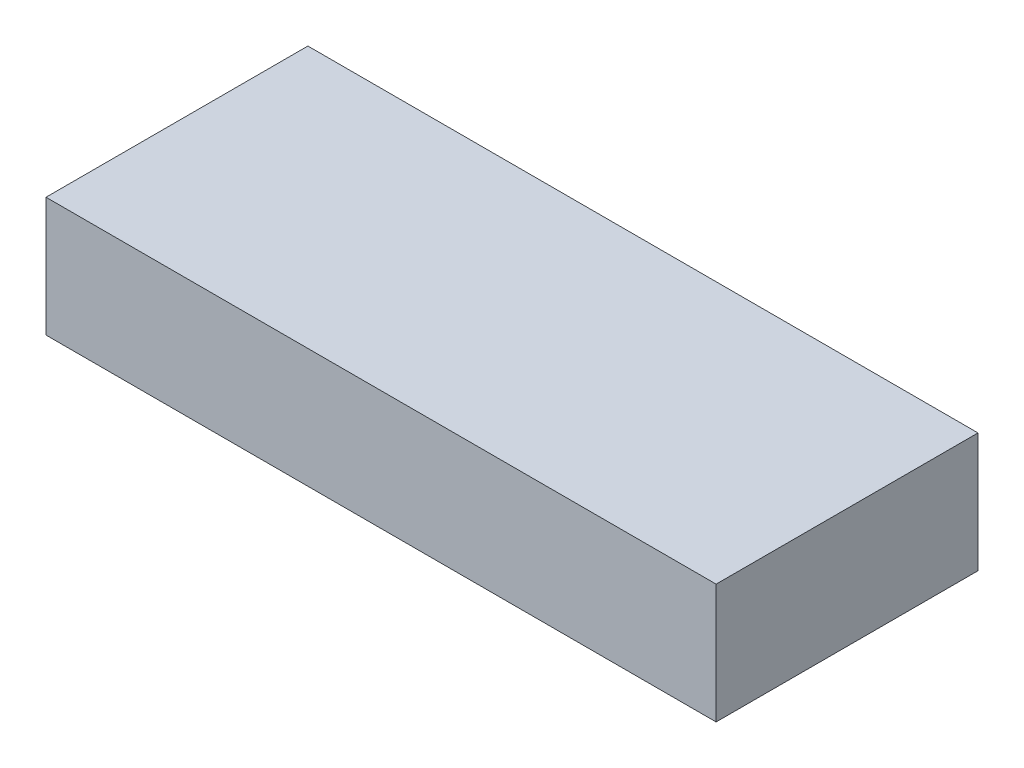
from build123d import *

# Parameters (mm, degrees)
SKETCH_1_W      = 87
SKETCH_1_H      = 34
EXTRUDE_1_DEPTH = 15.5


with BuildPart() as part:
    # ｽｹｯﾁ1 → ﾎﾞｽ - 押し出し1 (new body)
    with BuildSketch(Plane(origin=(0, 0, 0), x_dir=(1, 0, 0), z_dir=(0, 1, 0))):
        with Locations((43.5, 17)):
            Rectangle(SKETCH_1_W, SKETCH_1_H)
    extrude(amount=EXTRUDE_1_DEPTH)


solid = part.part
